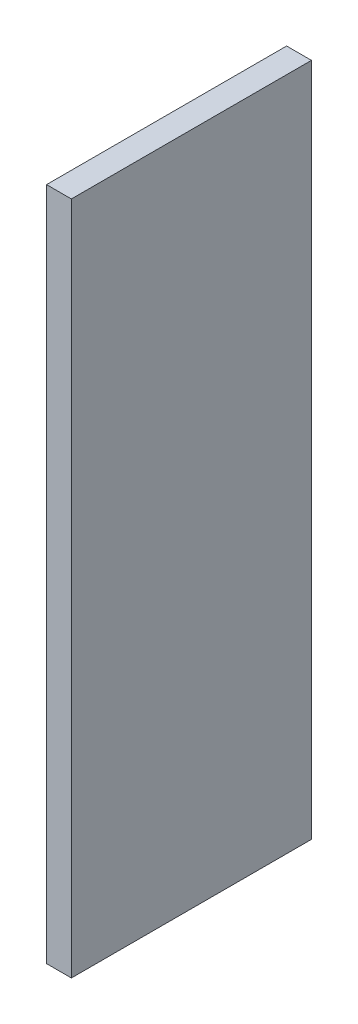
from build123d import *

# Parameters (mm, degrees)
SKETCH1_W           = 61.38418
SKETCH1_H           = 172.50918
BOSS_EXTRUDE1_DEPTH = 6.35


with BuildPart() as part:
    # Sketch1 → Boss-Extrude1 (new body)
    with BuildSketch(Plane(origin=(0, 0, 0), x_dir=(0, 0, -1), z_dir=(1, 0, 0))):
        with Locations((30.69209, 86.25459)):
            Rectangle(SKETCH1_W, SKETCH1_H)
    extrude(amount=BOSS_EXTRUDE1_DEPTH)


solid = part.part
